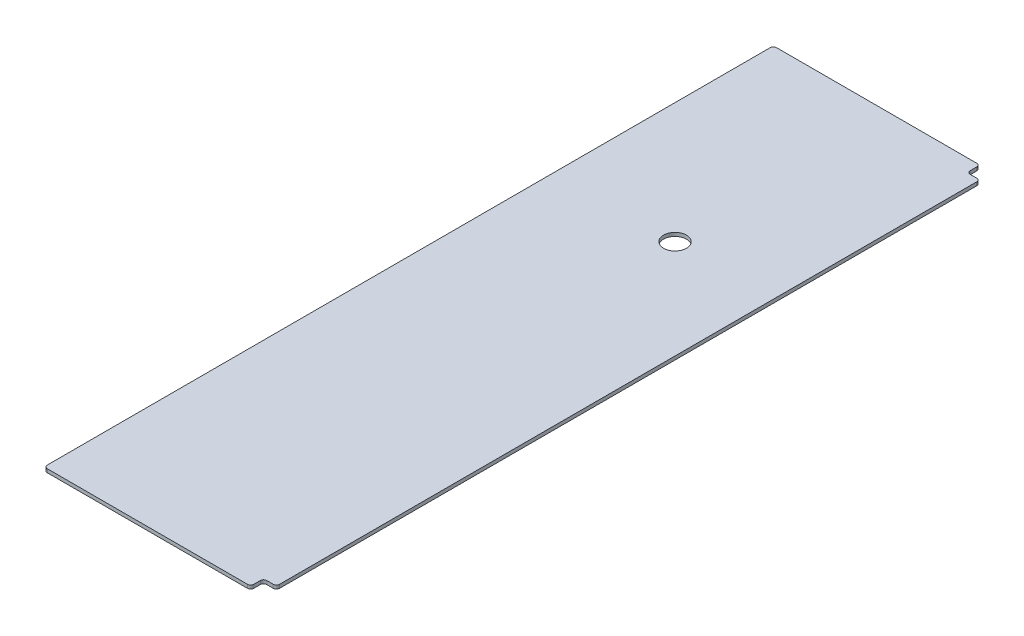
from build123d import *

# Parameters (mm, degrees)
SKETCH1_W           = 190.5
SKETCH1_H           = 609.6
BOSS_EXTRUDE1_DEPTH = 2.778125
SKETCH2_W           = 190.5
SKETCH2_H           = 17.78
CUT_EXTRUDE1_DEPTH  = 3.778125
SKETCH3_W           = 17.78
SKETCH3_H           = 574.04
CUT_EXTRUDE2_DEPTH  = 3.778125
SKETCH4_W           = 10.16
SKETCH4_H           = 10.16
CUT_EXTRUDE3_DEPTH  = 3.778125
FILLET1_R           = 2.54
SKETCH5_R           = 9
CUT_EXTRUDE4_DEPTH  = 3.778125


with BuildPart() as part:
    # Sketch1 → Boss-Extrude1 (new body)
    with BuildSketch(Plane(origin=(0, 0, 0), x_dir=(1, 0, 0), z_dir=(0, 1, 0))):
        with Locations((95.25, 304.8)):
            Rectangle(SKETCH1_W, SKETCH1_H)
    extrude(amount=BOSS_EXTRUDE1_DEPTH)

    # Sketch2 → Cut-Extrude1 (cut, through all)
    with BuildSketch(Plane(origin=(0, 2.778125, 0), x_dir=(1, 0, 0), z_dir=(0, 1, 0))):
        with Locations((95.25, 8.89)):
            Rectangle(SKETCH2_W, SKETCH2_H)
        with Locations((95.25, 600.71)):
            Rectangle(SKETCH2_W, SKETCH2_H)
    extrude(amount=-CUT_EXTRUDE1_DEPTH, mode=Mode.SUBTRACT)

    # Sketch3 → Cut-Extrude2 (cut, through all)
    with BuildSketch(Plane(origin=(0, 2.778125, 0), x_dir=(1, 0, 0), z_dir=(0, 1, 0))):
        with Locations((8.89, 304.8)):
            Rectangle(SKETCH3_W, SKETCH3_H)
    extrude(amount=-CUT_EXTRUDE2_DEPTH, mode=Mode.SUBTRACT)

    # Sketch4 → Cut-Extrude3 (cut, through all)
    with BuildSketch(Plane(origin=(0, 2.778125, 0), x_dir=(1, 0, 0), z_dir=(0, 1, 0))):
        with Locations((185.42, 586.74)):
            Rectangle(SKETCH4_W, SKETCH4_H)
        with Locations((185.42, 22.86)):
            Rectangle(SKETCH4_W, SKETCH4_H)
    extrude(amount=-CUT_EXTRUDE3_DEPTH, mode=Mode.SUBTRACT)

    # Fillet1
    fillet1_edges = [part.edges().sort_by_distance(p)[0] for p in [
        (17.78, 1.3890625, -591.82),
        (17.78, 1.3890625, -17.78),
        (190.5, 1.3890625, -581.66),
        (180.34, 1.3890625, -581.66),
        (180.34, 1.3890625, -591.82),
        (190.5, 1.3890625, -27.94),
        (180.34, 1.3890625, -17.78),
        (180.34, 1.3890625, -27.94),
    ]]
    fillet(fillet1_edges, radius=FILLET1_R)

    # Sketch5 → Cut-Extrude4 (cut, through all)
    with BuildSketch(Plane.XZ):
        with Locations((112.58, -419.599999967)):
            Circle(SKETCH5_R)
    extrude(amount=-CUT_EXTRUDE4_DEPTH, mode=Mode.SUBTRACT)


solid = part.part
